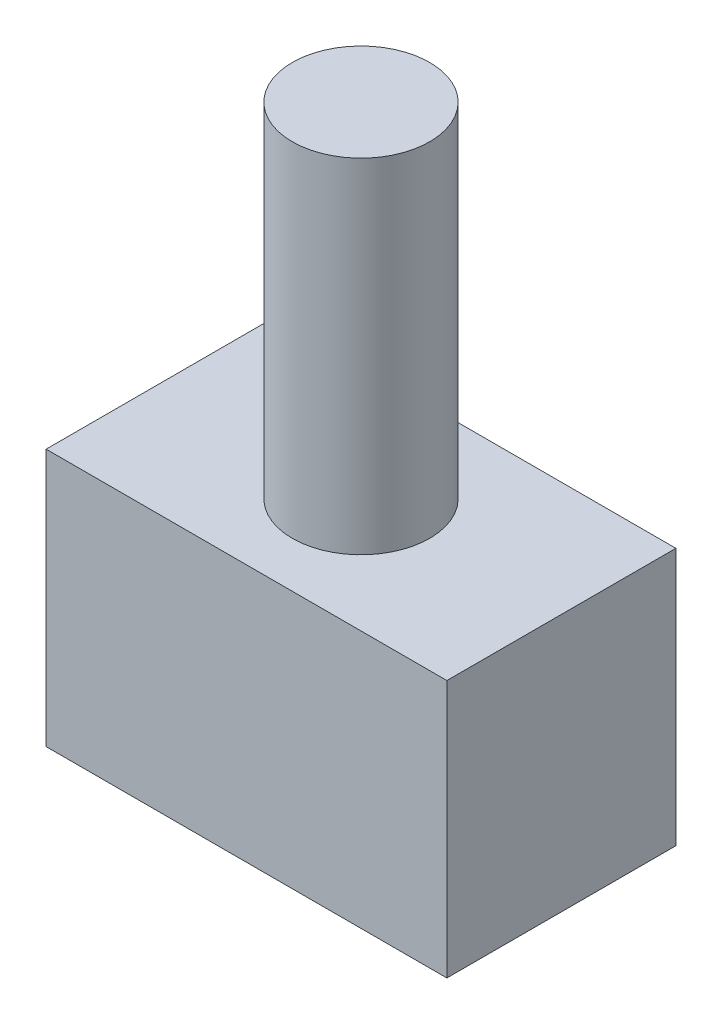
from build123d import *

# Parameters (mm, degrees)
SKETCH1_W      = 35
SKETCH1_H      = 20
EXTRUDE1_DEPTH = 22.5
SKETCH2_R      = 6
EXTRUDE2_DEPTH = 30


with BuildPart() as part:
    # Sketch1 → Extrude1 (new body)
    with BuildSketch(Plane(origin=(0, 0, 0), x_dir=(1, 0, 0), z_dir=(0, 1, 0))):
        with Locations((17.5, 10)):
            Rectangle(SKETCH1_W, SKETCH1_H)
    extrude(amount=-EXTRUDE1_DEPTH)

    # Sketch2 → Extrude2 (add)
    with BuildSketch(Plane(origin=(0, 0, 0), x_dir=(1, 0, 0), z_dir=(0, 1, 0))):
        with Locations(Location((17.5, 10, 0), (0, 0, 270))):  # turned: the seam where the file's is
            Circle(SKETCH2_R)
    extrude(amount=EXTRUDE2_DEPTH)


solid = part.part
